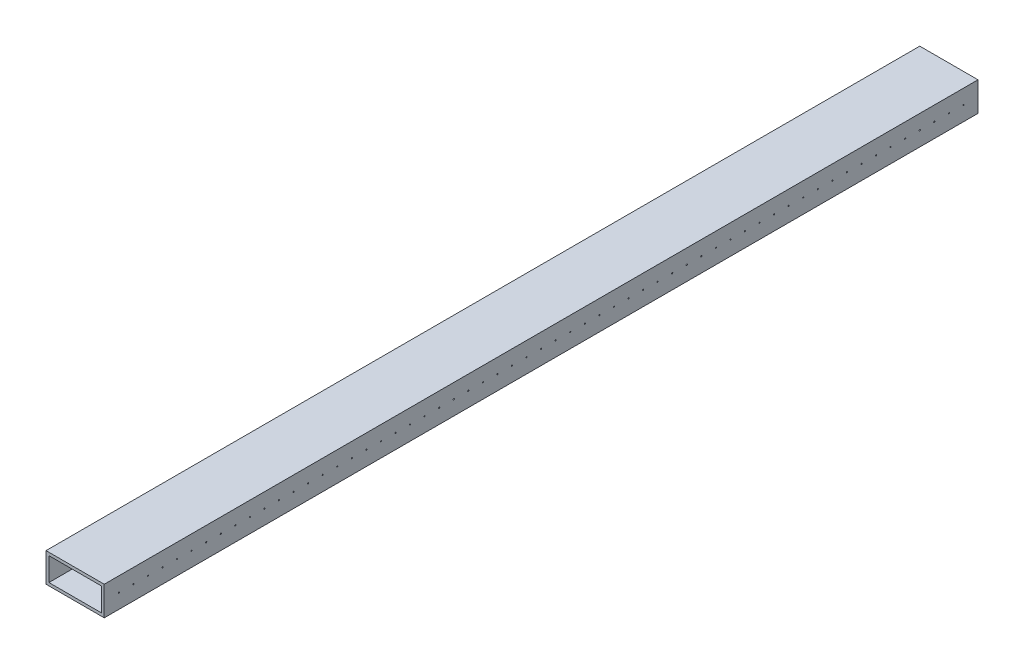
from build123d import *

# Parameters (mm, degrees)
SKETCH1_W           = 50.8
SKETCH1_H           = 25.4
SKETCH1_W_2         = 45.72
SKETCH1_H_2         = 20.32
BOSS_EXTRUDE1_DEPTH = 762
SKETCH2_R           = 0.5
CUT_EXTRUDE1_DEPTH  = 279.4


with BuildPart() as part:
    # Sketch1 → Boss-Extrude1 (new body)
    with BuildSketch(Plane.XY):
        with Locations((25.4, -12.7)):
            Rectangle(SKETCH1_W, SKETCH1_H)
        with Locations((25.4, -12.7)):
            Rectangle(SKETCH1_W_2, SKETCH1_H_2, mode=Mode.SUBTRACT)
    extrude(amount=BOSS_EXTRUDE1_DEPTH)

    # Sketch2 → Cut-Extrude1 (cut)
    with BuildSketch(Plane(origin=(50.8, 0, 0), x_dir=(0, 0, -1), z_dir=(1, 0, 0))):
        with Locations((-749.3, -12.7)):
            Circle(SKETCH2_R)
        with Locations((-736.6, -12.7)):
            Circle(SKETCH2_R)
        with Locations((-723.9, -12.7)):
            Circle(SKETCH2_R)
        with Locations((-711.2, -12.7)):
            Circle(SKETCH2_R)
        with Locations((-698.5, -12.7)):
            Circle(SKETCH2_R)
        with Locations((-685.8, -12.7)):
            Circle(SKETCH2_R)
        with Locations((-673.1, -12.7)):
            Circle(SKETCH2_R)
        with Locations((-660.4, -12.7)):
            Circle(SKETCH2_R)
        with Locations((-647.7, -12.7)):
            Circle(SKETCH2_R)
        with Locations((-635, -12.7)):
            Circle(SKETCH2_R)
        with Locations((-622.3, -12.7)):
            Circle(SKETCH2_R)
        with Locations((-609.6, -12.7)):
            Circle(SKETCH2_R)
        with Locations((-596.9, -12.7)):
            Circle(SKETCH2_R)
        with Locations((-584.2, -12.7)):
            Circle(SKETCH2_R)
        with Locations((-571.5, -12.7)):
            Circle(SKETCH2_R)
        with Locations((-558.8, -12.7)):
            Circle(SKETCH2_R)
        with Locations((-546.1, -12.7)):
            Circle(SKETCH2_R)
        with Locations((-533.4, -12.7)):
            Circle(SKETCH2_R)
        with Locations((-520.7, -12.7)):
            Circle(SKETCH2_R)
        with Locations((-508, -12.7)):
            Circle(SKETCH2_R)
        with Locations((-495.3, -12.7)):
            Circle(SKETCH2_R)
        with Locations((-482.6, -12.7)):
            Circle(SKETCH2_R)
        with Locations((-469.9, -12.7)):
            Circle(SKETCH2_R)
        with Locations((-457.2, -12.7)):
            Circle(SKETCH2_R)
        with Locations((-444.5, -12.7)):
            Circle(SKETCH2_R)
        with Locations((-431.8, -12.7)):
            Circle(SKETCH2_R)
        with Locations((-419.1, -12.7)):
            Circle(SKETCH2_R)
        with Locations((-406.4, -12.7)):
            Circle(SKETCH2_R)
        with Locations((-393.7, -12.7)):
            Circle(SKETCH2_R)
        with Locations((-381, -12.7)):
            Circle(SKETCH2_R)
        with Locations((-368.3, -12.7)):
            Circle(SKETCH2_R)
        with Locations((-355.6, -12.7)):
            Circle(SKETCH2_R)
        with Locations((-342.9, -12.7)):
            Circle(SKETCH2_R)
        with Locations((-330.2, -12.7)):
            Circle(SKETCH2_R)
        with Locations((-317.5, -12.7)):
            Circle(SKETCH2_R)
        with Locations((-304.8, -12.7)):
            Circle(SKETCH2_R)
        with Locations((-292.1, -12.7)):
            Circle(SKETCH2_R)
        with Locations((-279.4, -12.7)):
            Circle(SKETCH2_R)
        with Locations((-266.7, -12.7)):
            Circle(SKETCH2_R)
        with Locations((-254, -12.7)):
            Circle(SKETCH2_R)
        with Locations((-241.3, -12.7)):
            Circle(SKETCH2_R)
        with Locations((-228.6, -12.7)):
            Circle(SKETCH2_R)
        with Locations((-215.9, -12.7)):
            Circle(SKETCH2_R)
        with Locations((-203.2, -12.7)):
            Circle(SKETCH2_R)
        with Locations((-190.5, -12.7)):
            Circle(SKETCH2_R)
        with Locations((-177.8, -12.7)):
            Circle(SKETCH2_R)
        with Locations((-165.1, -12.7)):
            Circle(SKETCH2_R)
        with Locations((-152.4, -12.7)):
            Circle(SKETCH2_R)
        with Locations((-139.7, -12.7)):
            Circle(SKETCH2_R)
        with Locations((-127, -12.7)):
            Circle(SKETCH2_R)
        with Locations((-114.3, -12.7)):
            Circle(SKETCH2_R)
        with Locations((-101.6, -12.7)):
            Circle(SKETCH2_R)
        with Locations((-88.9, -12.7)):
            Circle(SKETCH2_R)
        with Locations((-76.2, -12.7)):
            Circle(SKETCH2_R)
        with Locations((-63.5, -12.7)):
            Circle(SKETCH2_R)
        with Locations((-50.8, -12.7)):
            Circle(SKETCH2_R)
        with Locations((-38.1, -12.7)):
            Circle(SKETCH2_R)
        with Locations((-25.4, -12.7)):
            Circle(SKETCH2_R)
        with Locations((-12.7, -12.7)):
            Circle(SKETCH2_R)
    extrude(amount=-CUT_EXTRUDE1_DEPTH, mode=Mode.SUBTRACT)


solid = part.part
